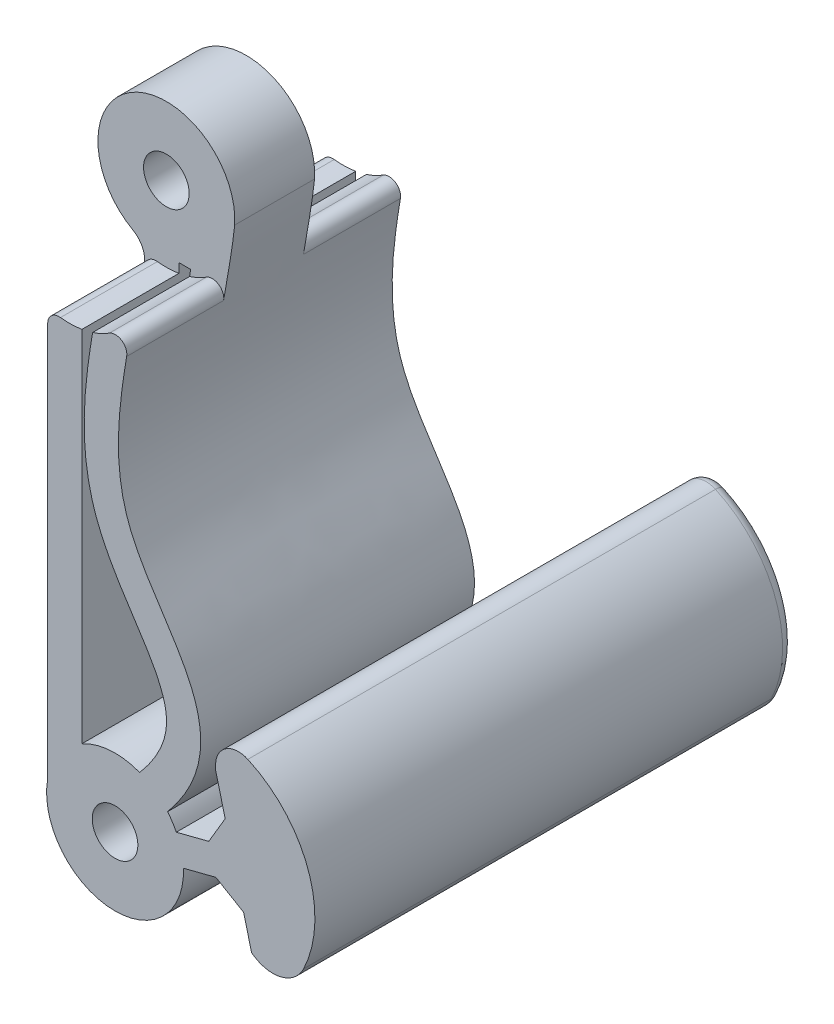
from build123d import *

# Parameters (mm, degrees)
SKETCH1_R                = 1
BOSS_EXTRUDE1_DEPTH      = 12
SKETCH2_R                = 3.3
CUT_EXTRUDE1_DEPTH       = 4.25
SKETCH3_R                = 3.3
CUT_EXTRUDE2_DEPTH       = 2.25
CUT_EXTRUDE2_DEPTH_BACK  = 2.25
BOSS_EXTRUDE4_DEPTH      = 12
BOSS_EXTRUDE4_DEPTH_BACK = 9
BOSS_EXTRUDE5_DEPTH      = 21
BOSS_EXTRUDE6_DEPTH      = 3.75
BOSS_EXTRUDE7_DEPTH      = 3.75
FILLET1_R                = 0.5
FILLET2_R                = 1
FILLET10_R               = 1.5
FILLET11_R               = 1
CHAMFER5_SIZE            = 1
FILLET12_R               = 1
FILLET13_R               = 0.5


with BuildPart() as part:
    # Sketch1 → Boss-Extrude1 (new body)
    with BuildSketch(Plane.XY):
        with BuildLine():
            Line((-2.048815827, 41.884151299), (-2.048815827, 23.656682303))
            ThreePointArc((-2.048815827, 23.656682303), (1.66754925, 20.218418642), (3.205412143, 25.042110601))
            add(Edge.make_bspline(
                [(1.896008332, 44.529660516), (1.616069448, 41.758878479), (-0.936917255, 33.955197005), (6.844694938, 29.417505011), (3.205412143, 25.042110601)],
                knots=[0, 0, 0, 0, 0.461184527, 1, 1, 1, 1], degree=3))
            ThreePointArc((1.896008332, 44.529660516), (-2.768270934, 47.220856283), (-2.048815827, 41.884151299))
        make_face()
        with Locations((-1.097343641, 44.729270045)):
            Circle(SKETCH1_R, mode=Mode.SUBTRACT)
        with Locations((0.902656359, 23.119270045)):
            Circle(SKETCH1_R, mode=Mode.SUBTRACT)
        with BuildLine():
            Line((-0.031319306, 41.884151299), (-0.548815827, 41.884151299))
            Line((-0.548815827, 41.884151299), (-0.548815827, 25.744765902))
            ThreePointArc((-0.548815827, 25.744765902), (0.697826573, 26.112269337), (1.982912704, 25.918028026))
            add(Edge.make_bspline(
                [(-0.031319306, 41.884151299), (-0.050798368, 41.769911378), (-0.110231132, 41.41757497), (-0.243210983, 40.585051968), (-0.402027872, 39.353261852), (-0.479087992, 37.828213551), (-0.375856847, 36.275358456), (0.009969142, 34.681069755), (0.941317901, 32.770668216), (2.035404053, 31.246938586), (2.80471042, 29.909471533), (3.128629571, 29.030940173), (3.19641087, 28.267404516), (3.032335606, 27.550309668), (2.666289508, 26.829120101), (2.334869511, 26.350170873), (2.106769915, 26.067173099), (2.026097439, 25.969974031), (1.996829195, 25.934759382), (1.982912704, 25.918028026)],
                knots=[0.149200089, 0.149200089, 0.149200089, 0.149200089, 0.165683382, 0.19960026, 0.265533433, 0.331466606, 0.397399778, 0.463332951, 0.529266124, 0.661132469, 0.727065642, 0.792998815, 0.858931987, 0.92486516, 0.957831746, 0.990798333, 0.999039979, 1.001358499, 1.00341891, 1.00341891, 1.00341891, 1.00341891], degree=3))
        make_face(mode=Mode.SUBTRACT)
    extrude(amount=BOSS_EXTRUDE1_DEPTH)

    # Sketch2 → Cut-Extrude1 (cut)
    with BuildSketch(Plane.XY.offset(12)):
        with Locations((-1.097343641, 44.729270045)):
            Circle(SKETCH2_R)
    cut_extrude1 = extrude(amount=-CUT_EXTRUDE1_DEPTH, mode=Mode.SUBTRACT)

    # Mirror1: Cut-Extrude1 across plane
    add(cut_extrude1.mirror(Plane.XY.offset(6)), mode=Mode.SUBTRACT)

    # Sketch3 → Cut-Extrude2 (cut, two sides)
    with BuildSketch(Plane.XY.offset(6)) as cut_extrude2_sk:
        with Locations((0.902656359, 23.119270045)):
            Circle(SKETCH3_R)
    extrude(amount=CUT_EXTRUDE2_DEPTH, mode=Mode.SUBTRACT)
    extrude(cut_extrude2_sk.sketch, amount=-CUT_EXTRUDE2_DEPTH_BACK, mode=Mode.SUBTRACT)



with BuildPart() as body_2:
    # Sketch6 → Boss-Extrude4 (new, two sides)
    with BuildSketch(Plane.XY) as boss_extrude4_sk:
        with BuildLine():
            Line((8.147666431, 20.643852604), (6.888843248, 21.528699147))
            ThreePointArc((6.888843248, 21.528699147), (8.054417737, 25.101419264), (5.311682387, 27.670523333))
            Line((5.311682387, 27.670523333), (5.311682387, 29.188822824))
            ThreePointArc((5.311682387, 29.188822824), (9.409872676, 25.805866797), (8.147666431, 20.643852604))
        make_face()
    extrude(amount=BOSS_EXTRUDE4_DEPTH)
    extrude(boss_extrude4_sk.sketch, amount=-BOSS_EXTRUDE4_DEPTH_BACK)

    # Sketch7 → Boss-Extrude5 (add)
    with BuildSketch(Plane.XY.offset(12)):
        with BuildLine():
            Line((5.311682387, 27.670523333), (6.888843248, 21.528699147))
            ThreePointArc((6.888843248, 21.528699147), (8.054417737, 25.101419264), (5.311682387, 27.670523333))
        make_face()
    extrude(amount=-BOSS_EXTRUDE5_DEPTH)


with BuildPart() as part_1:
    add(part.part)

    add(body_2.part)  # Boss-Extrude6 merges body 2
    # Sketch8 → Boss-Extrude6 (add)
    with BuildSketch(Plane.XY.offset(12)):
        Polygon((6.135349697, 24.462974926), (5.979899244, 25.068334452), (3.262106691, 24.370431694), (3.573007598, 23.15971264), (6.29080015, 23.857615399), align=None)
    extrude(amount=-BOSS_EXTRUDE6_DEPTH)

    # Sketch10 → Boss-Extrude7 (add)
    with BuildSketch(Plane(origin=(0, 0, 0), x_dir=(-1, 0, 0), z_dir=(0, 0, -1))):
        Polygon((-3.262106691, 24.370431694), (-3.573007598, 23.15971264), (-6.29080015, 23.857615399), (-6.135349697, 24.462974926), (-5.979899244, 25.068334452), align=None)
    extrude(amount=-BOSS_EXTRUDE7_DEPTH)

    # Fillet1
    fillet1_edges = [part_1.edges().sort_by_distance(p)[0] for p in [
        (1.670824854, 42.932817101, 9.875),
        (-2.048815827, 41.569412346, 9.875),
        (1.670824854, 42.932817101, 2.125),
        (-2.048815827, 41.569412346, 2.125),
    ]]
    fillet(fillet1_edges, radius=FILLET1_R)

    # Fillet2
    fillet2_edges = [part_1.edges().sort_by_distance(p)[0] for p in [
        (-2.048815827, 41.884151299, 6),
    ]]
    fillet(fillet2_edges, radius=FILLET2_R)

    # Fillet10
    fillet10_edges = [part_1.edges().sort_by_distance(p)[0] for p in [
        (8.147666431, 20.643852604, 1.5),
    ]]
    fillet(fillet10_edges, radius=FILLET10_R)

    # Fillet11
    fillet11_edges = [part_1.edges().sort_by_distance(p)[0] for p in [
        (-2.048815827, 24.595349967, 6),
    ]]
    fillet(fillet11_edges, radius=FILLET11_R)

    # Chamfer5
    chamfer5_edges = [part_1.edges().sort_by_distance(p)[0] for p in [
        (6.29080015, 23.857615399, 10.125),
        (5.979899244, 25.068334452, 10.125),
        (6.135349697, 24.462974926, 8.25),
        (6.135349697, 24.462974926, 0),
        (5.979899244, 25.068334452, 1.875),
        (6.135349697, 24.462974926, 3.75),
        (6.29080015, 23.857615399, 1.875),
    ]]
    chamfer(chamfer5_edges, length=CHAMFER5_SIZE)

    # Fillet12
    fillet12_edges = [part_1.edges().sort_by_distance(p)[0] for p in [
        (5.311682387, 29.188822824, 1.5),
    ]]
    fillet(fillet12_edges, radius=FILLET12_R)

    # Fillet13
    fillet13_edges = [part_1.edges().sort_by_distance(p)[0] for p in [
        (6.921467432, 21.505767097, -9),
        (9.36399081, 25.937907991, -9),
        (8.194027009, 21.258237643, -9),
        (5.311682387, 27.773240907, -9),
        (5.769381502, 28.716142835, -9),
    ]]
    fillet(fillet13_edges, radius=FILLET13_R)


solid = part_1.part
